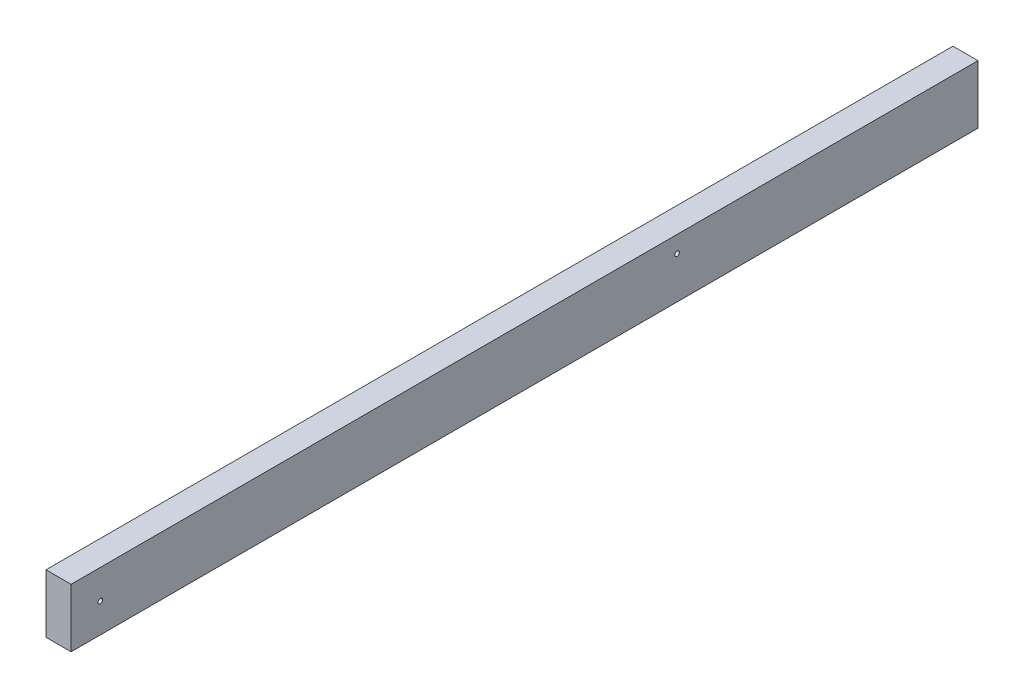
from build123d import *

# Parameters (mm, degrees)
SKETCH1_W                       = 38.1
SKETCH1_H                       = 88.9
BOSS_EXTRUDE1_DEPTH             = 1377.95
F_9_32_0_28125_DIAMETER_HOLE1_D = 7.14375


with BuildPart() as part:
    # Sketch1 → Boss-Extrude1 (new body)
    with BuildSketch(Plane.XY):
        Rectangle(SKETCH1_W, SKETCH1_H)
    extrude(amount=BOSS_EXTRUDE1_DEPTH)

    # 9/32 (0.28125) Diameter Hole1 (through all)
    with Locations(Plane(origin=(19.05, 0, 0), x_dir=(0, 0, -1), z_dir=(1, 0, 0))):
        with Locations((-1333.5, 0), (-457.2, 19.05)):
            Hole(F_9_32_0_28125_DIAMETER_HOLE1_D / 2)


solid = part.part
